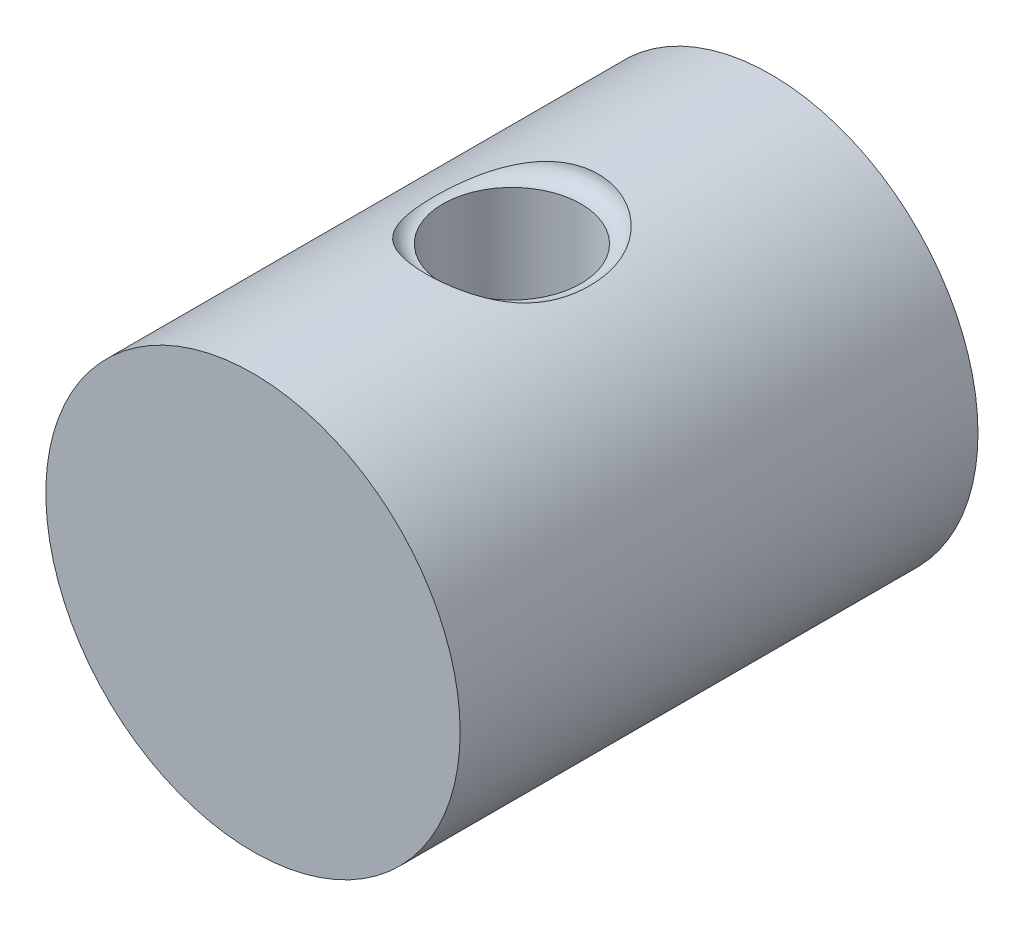
from build123d import *

# Parameters (mm, degrees)
SZKIC1_R                    = 12
DODANIE_WYCI_GNI_CIE1_DEPTH = 15
OTW_R_8_0_8_1_D             = 8
SZKIC5_R                    = 1


with BuildPart() as part:
    # Szkic1 → Dodanie-wyci_gni_cie1 (new body, symmetric)
    with BuildSketch(Plane.XY):
        Circle(SZKIC1_R)
    extrude(amount=DODANIE_WYCI_GNI_CIE1_DEPTH, both=True)

    # Otw_r _8.0 _8_1 (through all)
    with Locations(Plane(origin=(0, 12, 0), x_dir=(1, 0, 0), z_dir=(0, 1, 0))):
        with Locations((0, 0)):
            Hole(OTW_R_8_0_8_1_D / 2)

    # Szkic5 → Wyci_cie-obr_t1 (revolve, cut)
    with BuildSketch(Plane(origin=(0, 0, 0), x_dir=(0, 0, -1), z_dir=(1, 0, 0))):
        with Locations((-4, 12)):
            Circle(SZKIC5_R)
    revolve(axis=Axis((0, -12, 0), (0, 1, 0)), mode=Mode.SUBTRACT)


solid = part.part
